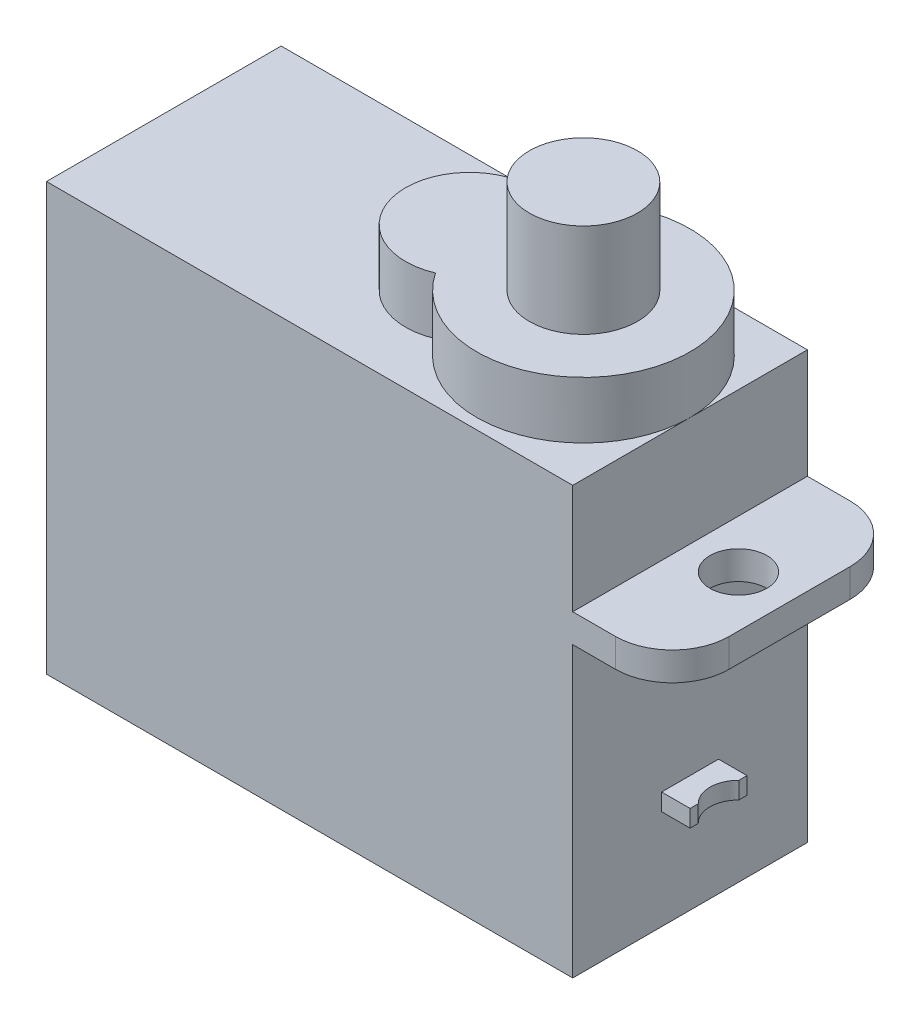
from build123d import *

# Parameters (mm, degrees)
SKETCH_1_W          = 18.5
SKETCH_1_H          = 8.25
EXTRUDE_1_DEPTH     = 15
SKETCH_2_R          = 3.75
EXTRUDE_2_DEPTH     = 2
SKETCH_3_R          = 2.25
EXTRUDE_3_DEPTH     = 2
SKETCH_4_R          = 1.9
EXTRUDE_4_DEPTH     = 3.3
SKETCH_5_W          = 2
SKETCH_5_H          = 0.6
EXTRUDE_5_DEPTH     = 1
SKETCH_6_W          = 25.5
SKETCH_6_H          = 8.25
EXTRUDE_6_DEPTH     = 1
SKETCH_7_R          = 1
CUT_EXTRUDE_1_DEPTH = 12.15
FILLET_1_R          = 2
SKETCH_8_W          = 5.807515018
SKETCH_8_H          = 9.098766066
CUT_EXTRUDE_2_DEPTH = 2


with BuildPart() as part:
    # 草图1 → 凸台-拉伸1 (new body)
    with BuildSketch(Plane(origin=(0, 0, 0), x_dir=(1, 0, 0), z_dir=(0, 1, 0))):
        Rectangle(SKETCH_1_W, SKETCH_1_H)
    extrude(amount=EXTRUDE_1_DEPTH)

    # 草图2 → 凸台-拉伸2 (add)
    with BuildSketch(Plane(origin=(0, 15, 0), x_dir=(1, 0, 0), z_dir=(0, 1, 0))):
        with Locations((5.5, 0)):
            Circle(SKETCH_2_R)
    extrude(amount=EXTRUDE_2_DEPTH)

    # 草图3 → 凸台-拉伸3 (add)
    with BuildSketch(Plane(origin=(0, 15, 0), x_dir=(1, 0, 0), z_dir=(0, 1, 0))):
        with Locations((1.5, 0)):
            Circle(SKETCH_3_R)
    extrude(amount=EXTRUDE_3_DEPTH)

    # 草图4 → 凸台-拉伸4 (add)
    with BuildSketch(Plane(origin=(0, 17, 0), x_dir=(1, 0, 0), z_dir=(0, 1, 0))):
        with Locations((5.5, 0)):
            Circle(SKETCH_4_R)
    extrude(amount=EXTRUDE_4_DEPTH)

    # 草图5 → 凸台-拉伸5 (add)
    with BuildSketch(Plane(origin=(9.25, 0, 0), x_dir=(0, 0, -1), z_dir=(1, 0, 0))):
        with Locations((0, 3.8)):
            Rectangle(SKETCH_5_W, SKETCH_5_H)
    extrude(amount=EXTRUDE_5_DEPTH)

    # 草图6 → 凸台-拉伸6 (add)
    with BuildSketch(Plane(origin=(0, 10.15, 0), x_dir=(1, 0, 0), z_dir=(0, 1, 0))):
        Rectangle(SKETCH_6_W, SKETCH_6_H)
    extrude(amount=EXTRUDE_6_DEPTH)

    # 草图7 → 切除-拉伸1 (cut, through all)
    with BuildSketch(Plane(origin=(0, 11.15, 0), x_dir=(1, 0, 0), z_dir=(0, 1, 0))):
        with Locations((-10.95, 0)):
            Circle(SKETCH_7_R)
        with Locations((10.95, 0)):
            Circle(SKETCH_7_R)
    extrude(amount=-CUT_EXTRUDE_1_DEPTH, mode=Mode.SUBTRACT)

    # 圆角1
    fillet_1_edges = [part.edges().sort_by_distance(p)[0] for p in [
        (-12.75, 10.65, 4.125),
        (12.75, 10.65, -4.125),
        (-12.75, 10.65, -4.125),
        (12.75, 10.65, 4.125),
    ]]
    fillet(fillet_1_edges, radius=FILLET_1_R)

    # 草图8 → 切除-拉伸2 (cut)
    with BuildSketch(Plane(origin=(0, 11.15, 0), x_dir=(1, 0, 0), z_dir=(0, 1, 0))):
        with Locations((-12.153757509, 0.424383033)):
            Rectangle(SKETCH_8_W, SKETCH_8_H)
    extrude(amount=-CUT_EXTRUDE_2_DEPTH, mode=Mode.SUBTRACT)


solid = part.part
